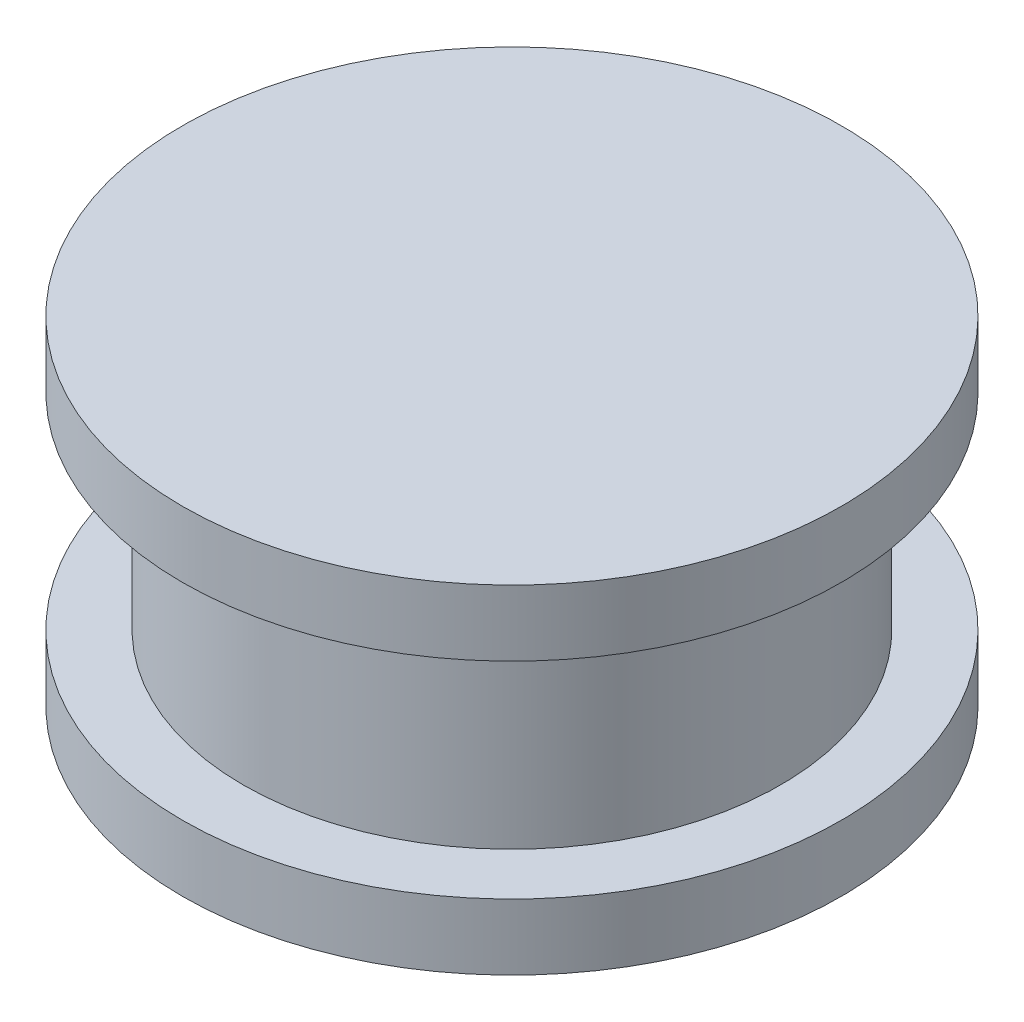
from build123d import *


with BuildPart() as part:
    # Sketch2 → Revolve1 (revolve)
    with BuildSketch(Plane.XY):
        Polygon((0, 0), (12.7, 0), (12.7, 2.54), (10.3505, 2.54), (10.3505, 10.4775), (12.7, 10.4775), (12.7, 13.0175), (0, 13.0175), align=None)
    revolve(axis=Axis((0, 13.0175, 0), (0, -1, 0)))


solid = part.part
